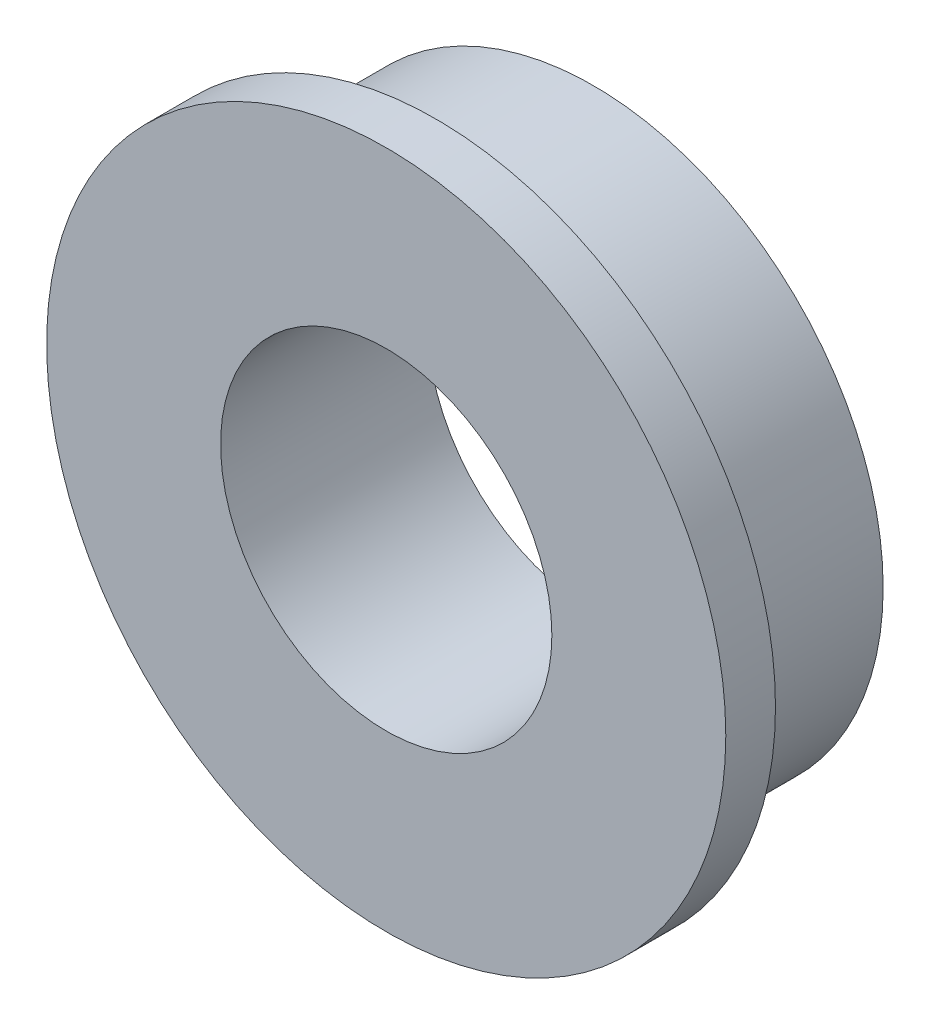
from build123d import *

# Parameters (mm, degrees)
SKETCH_1_R      = 3.5
SKETCH_1_R_2    = 2
EXTRUDE_1_DEPTH = 1.9
SKETCH_2_R      = 4.1
SKETCH_2_R_2    = 2
EXTRUDE_3_DEPTH = 0.6


with BuildPart() as part:
    # 草图1 → 凸台-拉伸1 (new body)
    with BuildSketch(Plane.XY):
        Circle(SKETCH_1_R)
        Circle(SKETCH_1_R_2, mode=Mode.SUBTRACT)
    extrude(amount=EXTRUDE_1_DEPTH)

    # 草图2 → 凸台-拉伸3 (add)
    with BuildSketch(Plane.XY.offset(1.9)):
        Circle(SKETCH_2_R)
        Circle(SKETCH_2_R_2, mode=Mode.SUBTRACT)
    extrude(amount=EXTRUDE_3_DEPTH)


solid = part.part
